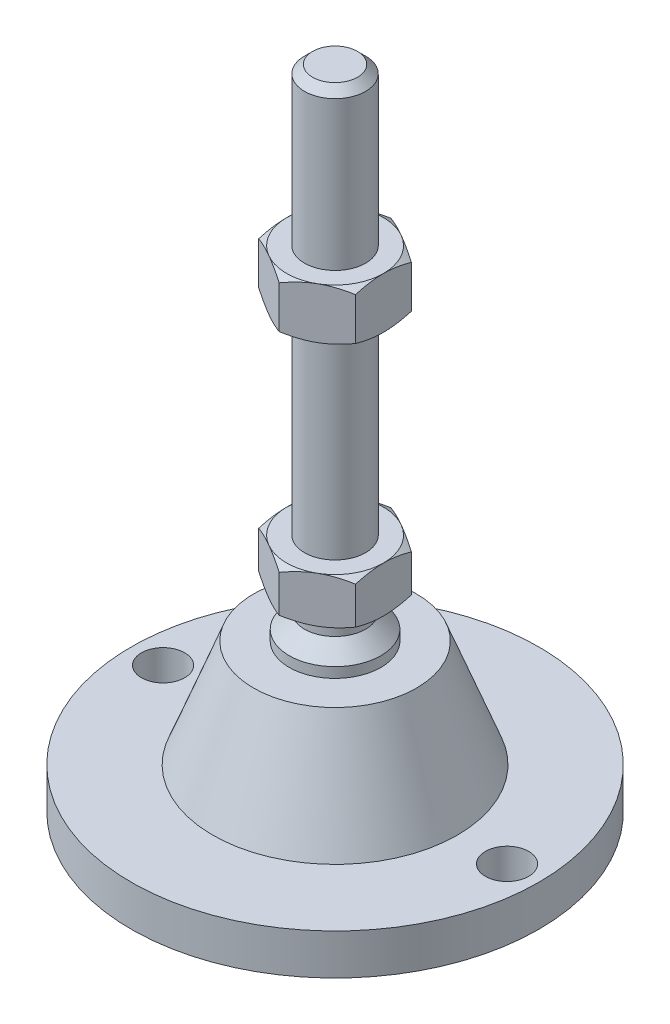
from build123d import *

# Parameters (mm, degrees)
EXTRUDE_1_DEPTH     = 9
EXTRUDE_2_DEPTH     = 10
SKETCH_5_R          = 4.25
CUT_EXTRUDE_1_DEPTH = 9


with BuildPart() as part:
    # Эскиз1 → Повернуть1 (revolve)
    with BuildSketch(Plane.XY, mode=Mode.PRIVATE) as revolve_1_sk:
        Polygon((0, 0), (-40, 0), (-40, 8), (-24, 8), (-16, 29), (-9, 29), (-9, 31), (-6, 34), (-6, 38), (-6, 47), (-6, 125.4), (-4.4, 127), (0, 127), align=None)
    revolve(revolve_1_sk.sketch.rotate(Axis((0, 0, 0), (0, 1, 0)), 180), axis=Axis((0, 0, 0), (0, 1, 0)))  # turned: the seam where the file's is

    # Эскиз2 → Бобышка-Вытянуть1 (add)
    with BuildSketch(Plane(origin=(0, 38, 0), x_dir=(1, 0, 0), z_dir=(0, 1, 0))):
        Polygon((0, 10.969655115), (-9.5, 5.484827557), (-9.5, -5.484827557), (0, -10.969655115), (9.5, -5.484827557), (9.5, 5.484827557), align=None)
    extrude(amount=EXTRUDE_1_DEPTH)

    # Эскиз3 → Бобышка-Вытянуть2 (add)
    with BuildSketch(Plane(origin=(0, 86.2, 0), x_dir=(1, 0, 0), z_dir=(0, 1, 0))):
        Polygon((9.5, 5.484827557), (0, 10.969655115), (-9.5, 5.484827557), (-9.5, -5.484827557), (0, -10.969655115), (9.5, -5.484827557), align=None)
    extrude(amount=EXTRUDE_2_DEPTH)

    # Эскиз4 → Вырез-Повернуть2 (revolve, cut)
    with BuildSketch(Plane.XY, mode=Mode.PRIVATE) as cut_revolve_2_sk:
        Polygon((-18.160254038, 96.2), (-9.5, 96.2), (-18.160254038, 91.2), align=None)
        Polygon((-18.160254038, 86.2), (-18.160254038, 91.2), (-9.5, 86.2), align=None)
        Polygon((-17.294228634, 47), (-17.294228634, 42.5), (-9.5, 47), align=None)
        Polygon((-17.294228634, 42.5), (-17.294228634, 38), (-9.5, 38), align=None)
    revolve(cut_revolve_2_sk.sketch.rotate(Axis((0, 127, 0), (0, -1, 0)), 180), axis=Axis((0, 127, 0), (0, -1, 0)), mode=Mode.SUBTRACT)  # turned: the seam where the file's is

    # Эскиз5 → Вырез-Вытянуть1 (cut, through all)
    with BuildSketch(Plane(origin=(0, 8, 0), x_dir=(1, 0, 0), z_dir=(0, 1, 0))):
        with Locations(Location((-33.75, 0, 0), (0, 0, 180))):  # turned: the seam where the file's is
            Circle(SKETCH_5_R)
        with Locations(Location((33.75, 0, 0), (0, 0, 180))):  # turned: the seam where the file's is
            Circle(SKETCH_5_R)
    extrude(amount=-CUT_EXTRUDE_1_DEPTH, mode=Mode.SUBTRACT)


solid = part.part
